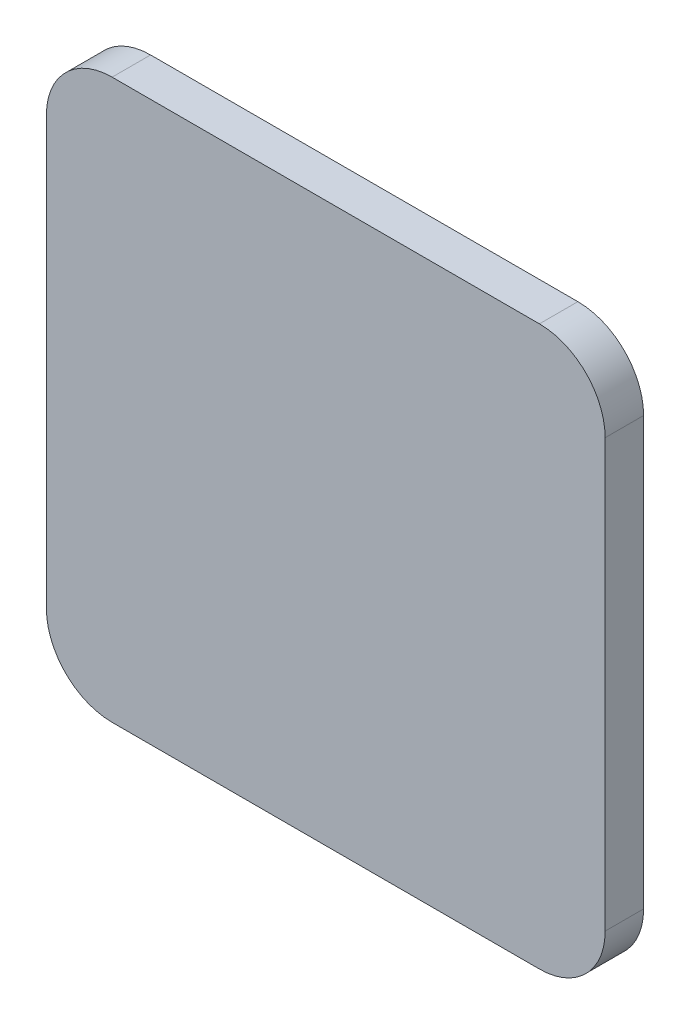
from build123d import *

# Parameters (mm, degrees)
BOSS_EXTRUDE1_DEPTH = 5.85


with BuildPart() as part:
    # Sketch1 → Boss-Extrude1 (new body)
    with BuildSketch(Plane.XY):
        with BuildLine():
            Line((-50.218321512, -95.19612962), (14.781678488, -95.19612962))
            ThreePointArc((14.781678488, -95.19612962), (21.8527463, -92.267197431), (24.781678488, -85.19612962))
            Line((24.781678488, -85.19612962), (24.781678488, -20.19612962))
            ThreePointArc((24.781678488, -20.19612962), (21.8527463, -13.125061808), (14.781678488, -10.19612962))
            Line((14.781678488, -10.19612962), (-50.218321512, -10.19612962))
            ThreePointArc((-50.218321512, -10.19612962), (-57.289389324, -13.125061808), (-60.218321512, -20.19612962))
            Line((-60.218321512, -20.19612962), (-60.218321512, -85.19612962))
            ThreePointArc((-60.218321512, -85.19612962), (-57.289389324, -92.267197431), (-50.218321512, -95.19612962))
        make_face()
    extrude(amount=BOSS_EXTRUDE1_DEPTH)


solid = part.part
